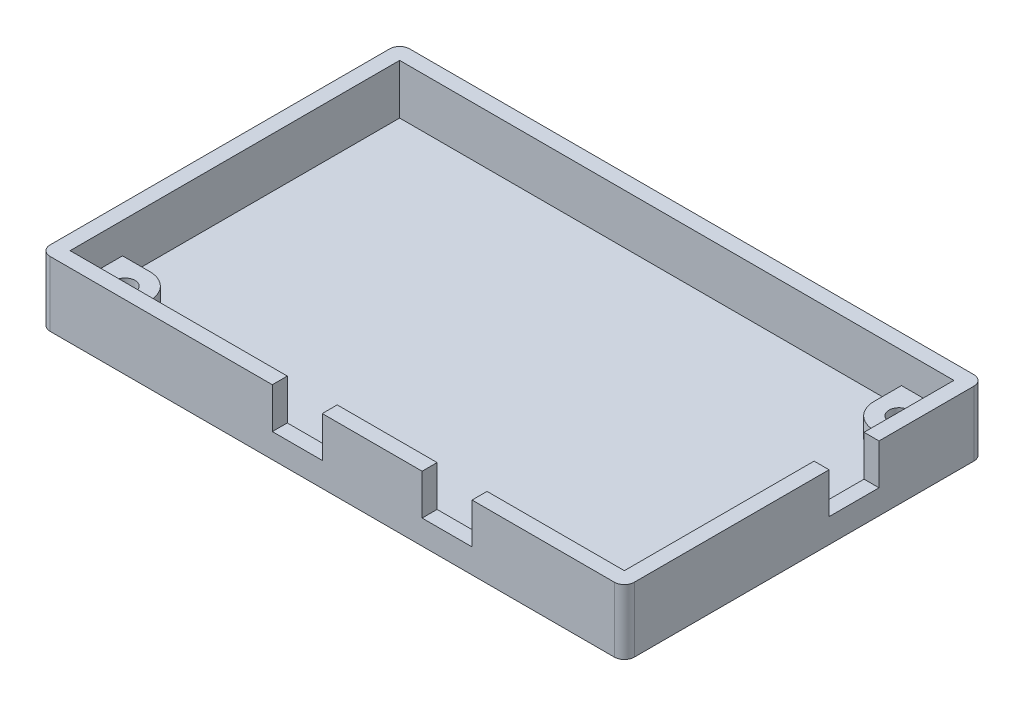
from build123d import *

# Parameters (mm, degrees)
SKETCH1_W           = 117
SKETCH1_H           = 72
BOSS_EXTRUDE1_DEPTH = 3
SKETCH1_5_W         = 117
SKETCH1_5_H         = 72
SKETCH1_5_W_2       = 111
SKETCH1_5_H_2       = 66
BOSS_EXTRUDE2_DEPTH = 10
BOSS_EXTRUDE3_DEPTH = 3.85
SKETCH3_R           = 2
CUT_EXTRUDE1_DEPTH  = 4.78
FILLET1_R           = 2
SKETCH4_W           = 10
SKETCH4_H           = 8.13
CUT_EXTRUDE2_DEPTH  = 134.372598385
SKETCH5_W           = 10
SKETCH5_H           = 8.13
CUT_EXTRUDE3_DEPTH  = 134.203791237


with BuildPart() as part:
    # Sketch1 → Boss-Extrude1 (new body)
    with BuildSketch(Plane(origin=(0, 0, 0), x_dir=(1, 0, 0), z_dir=(0, 1, 0))):
        with Locations((55, 32.5)):
            Rectangle(SKETCH1_W, SKETCH1_H)
    extrude(amount=-BOSS_EXTRUDE1_DEPTH)

    # Sketch1_5 → Boss-Extrude2 (add)
    with BuildSketch(Plane(origin=(0, 0, 0), x_dir=(1, 0, 0), z_dir=(0, 1, 0))):
        with Locations((55, 32.5)):
            Rectangle(SKETCH1_5_W, SKETCH1_5_H)
        with Locations((55, 32.5)):
            Rectangle(SKETCH1_5_W_2, SKETCH1_5_H_2, mode=Mode.SUBTRACT)
    extrude(amount=BOSS_EXTRUDE2_DEPTH)

    # Sketch2 → Boss-Extrude3 (add)
    with BuildSketch(Plane(origin=(0, 0, 0), x_dir=(1, 0, 0), z_dir=(0, 1, 0))):
        with BuildLine():
            Line((110.5, 65.5), (100, 65.5))
            Line((100, 65.5), (100, 60))
            ThreePointArc((100, 60), (101.464466094, 56.464466094), (105, 55))
            Line((105, 55), (110.5, 55))
            Line((110.5, 55), (110.5, 65.5))
        make_face()
        with BuildLine():
            Line((-0.5, -0.5), (10, -0.5))
            Line((10, -0.5), (10, 5))
            ThreePointArc((10, 5), (8.535533906, 8.535533906), (5, 10))
            Line((5, 10), (-0.5, 10))
            Line((-0.5, 10), (-0.5, -0.5))
        make_face()
    extrude(amount=BOSS_EXTRUDE3_DEPTH)

    # Sketch3 → Cut-Extrude1 (cut)
    with BuildSketch(Plane(origin=(0, 3.85, 0), x_dir=(1, 0, 0), z_dir=(0, 1, 0))):
        with Locations((105, 60)):
            Circle(SKETCH3_R)
        with Locations((5, 5)):
            Circle(SKETCH3_R)
    extrude(amount=-CUT_EXTRUDE1_DEPTH, mode=Mode.SUBTRACT)

    # Fillet1
    fillet1_edges = [part.edges().sort_by_distance(p)[0] for p in [
        (113.5, 3.5, 3.5),
        (-3.5, 3.5, 3.5),
        (-3.5, 3.5, -68.5),
        (113.5, 3.5, -68.5),
    ]]
    fillet(fillet1_edges, radius=FILLET1_R)

    # Sketch4 → Cut-Extrude2 (cut, through all)
    with BuildSketch(Plane.ZY.offset(-110.5)):
        with Locations((-42.5, 5.935)):
            Rectangle(SKETCH4_W, SKETCH4_H)
    extrude(amount=-CUT_EXTRUDE2_DEPTH, mode=Mode.SUBTRACT)

    # Sketch5 → Cut-Extrude3 (cut, through all)
    with BuildSketch(Plane(origin=(0, 0, 0.5), x_dir=(-1, 0, 0), z_dir=(0, 0, -1))):
        with Locations((-78, 5.935)):
            Rectangle(SKETCH5_W, SKETCH5_H)
        with Locations((-48, 5.935)):
            Rectangle(SKETCH5_W, SKETCH5_H)
    extrude(amount=-CUT_EXTRUDE3_DEPTH, mode=Mode.SUBTRACT)


solid = part.part
